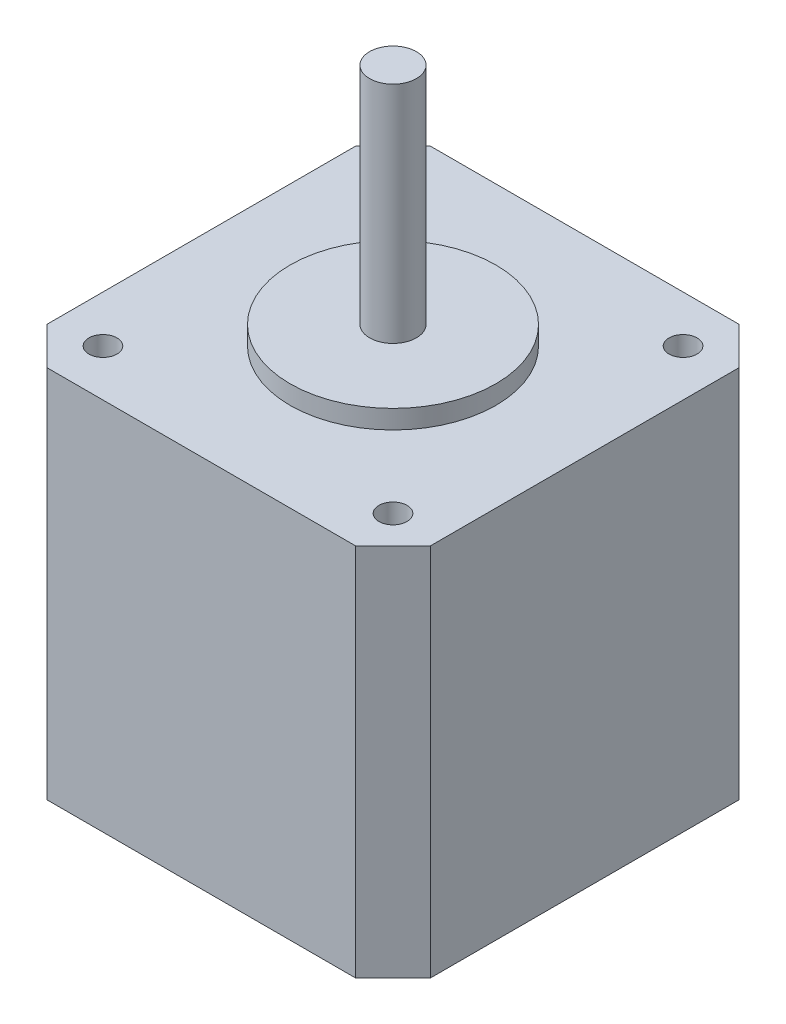
from build123d import *

# Parameters (mm, degrees)
BOSS_EXTRUDE1_DEPTH = 40
SKETCH2_R           = 11
BOSS_EXTRUDE2_DEPTH = 2
SKETCH3_R           = 2.5
BOSS_EXTRUDE3_DEPTH = 24
SKETCH4_R           = 1.5
CUT_EXTRUDE1_DEPTH  = 5


with BuildPart() as part:
    # Sketch1 → Boss-Extrude1 (new body)
    with BuildSketch(Plane(origin=(0, 0, 0), x_dir=(1, 0, 0), z_dir=(0, 1, 0))):
        Polygon((-16.5, 20.5), (-20.5, 16.5), (-20.5, -16.5), (-16.5, -20.5), (16.5, -20.5), (20.5, -16.5), (20.5, 16.5), (16.5, 20.5), align=None)
    extrude(amount=BOSS_EXTRUDE1_DEPTH)

    # Sketch2 → Boss-Extrude2 (add)
    with BuildSketch(Plane(origin=(0, 40, 0), x_dir=(1, 0, 0), z_dir=(0, 1, 0))):
        Circle(SKETCH2_R)
    extrude(amount=BOSS_EXTRUDE2_DEPTH)

    # Sketch3 → Boss-Extrude3 (add)
    with BuildSketch(Plane(origin=(0, 42, 0), x_dir=(1, 0, 0), z_dir=(0, 1, 0))):
        Circle(SKETCH3_R)
    extrude(amount=BOSS_EXTRUDE3_DEPTH)

    # Sketch4 → Cut-Extrude1 (cut)
    with BuildSketch(Plane(origin=(0, 40, 0), x_dir=(1, 0, 0), z_dir=(0, 1, 0))):
        with Locations((-15.5, 15.5)):
            Circle(SKETCH4_R)
        with Locations((15.5, 15.5)):
            Circle(SKETCH4_R)
        with Locations((15.5, -15.5)):
            Circle(SKETCH4_R)
        with Locations((-15.5, -15.5)):
            Circle(SKETCH4_R)
    extrude(amount=-CUT_EXTRUDE1_DEPTH, mode=Mode.SUBTRACT)


solid = part.part
